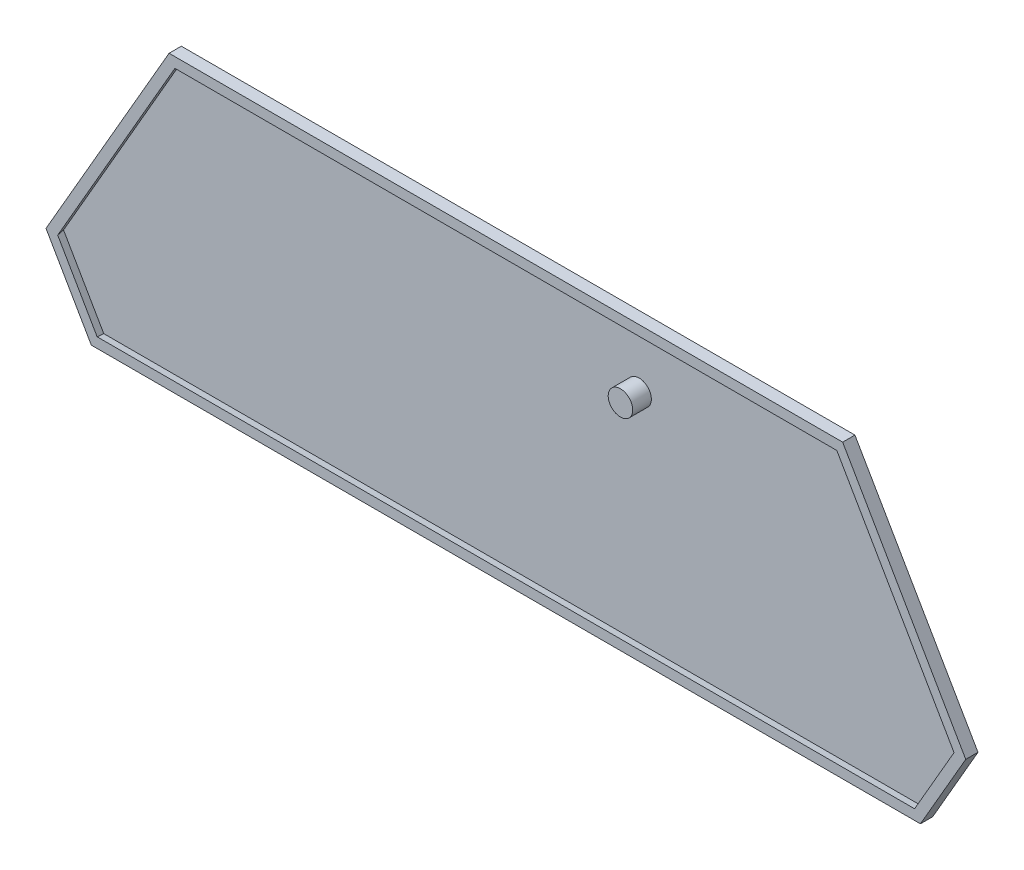
from build123d import *

# Parameters (mm, degrees)
BOSS_EXTRU_1_DEPTH              = 1
EXTRU_MINCE1_DEPTH              = 1.5
EXTRU_MINCE1_TAPER              = -10
ENL_V_DE_MAT_EXTRU_MINCE1_DEPTH = 3.5000001
ESQUISSE4_R                     = 2.5
BOSS_EXTRU_2_DEPTH              = 3.8


with BuildPart() as part:
    # Esquisse1 → Boss.-Extru.1 (new body)
    with BuildSketch(Plane.XY):
        Polygon((-84.524791386, -59.467077727), (2.7, -59.467077727), (84.524791386, -59.467077727), (93.762395693, -43.467077727), (68.666666667, 0), (-68.666666667, 0), (-93.762395693, -43.467077727), align=None)
    extrude(amount=BOSS_EXTRU_1_DEPTH)

    # Esquisse2 → Extru.-Mince1 (add)
    with BuildSketch(Plane.XY.offset(1)):
        Polygon((-93.762395693, -43.467077727), (-84.524791386, -59.467077727), (84.524791386, -59.467077727), (93.762395693, -43.467077727), (68.666666667, 0), (-68.666666667, 0), align=None)
        Polygon((-91.683934724, -43.467077727), (-83.485560901, -57.667077727), (83.485560901, -57.667077727), (91.683934724, -43.467077727), (67.627436182, -1.8), (-67.627436182, -1.8), align=None, mode=Mode.SUBTRACT)
    extrude(amount=EXTRU_MINCE1_DEPTH, taper=EXTRU_MINCE1_TAPER)

    # Esquisse3 → Enlèv. de mat.-Extru.-Mince1 (cut, through all)
    with BuildSketch(Plane(origin=(0, 0, 0), x_dir=(-1, 0, 0), z_dir=(0, 0, -1))):
        Polygon((85.621756897, -61.367077727), (95.956326716, -43.467077727), (69.763632178, 1.9), (-69.763632178, 1.9), (-95.956326716, -43.467077727), (-85.621756897, -61.367077727), align=None)
        Polygon((84.524791386, -59.467077727), (93.762395693, -43.467077727), (68.666666667, 0), (-68.666666667, 0), (-93.762395693, -43.467077727), (-84.524791386, -59.467077727), align=None, mode=Mode.SUBTRACT)
    extrude(amount=-ENL_V_DE_MAT_EXTRU_MINCE1_DEPTH, mode=Mode.SUBTRACT)

    # Esquisse4 → Boss.-Extru.2 (add)
    with BuildSketch(Plane.XY.offset(1)):
        with Locations((25.665479371, -13.424541306)):
            Circle(ESQUISSE4_R)
    extrude(amount=BOSS_EXTRU_2_DEPTH)


solid = part.part
